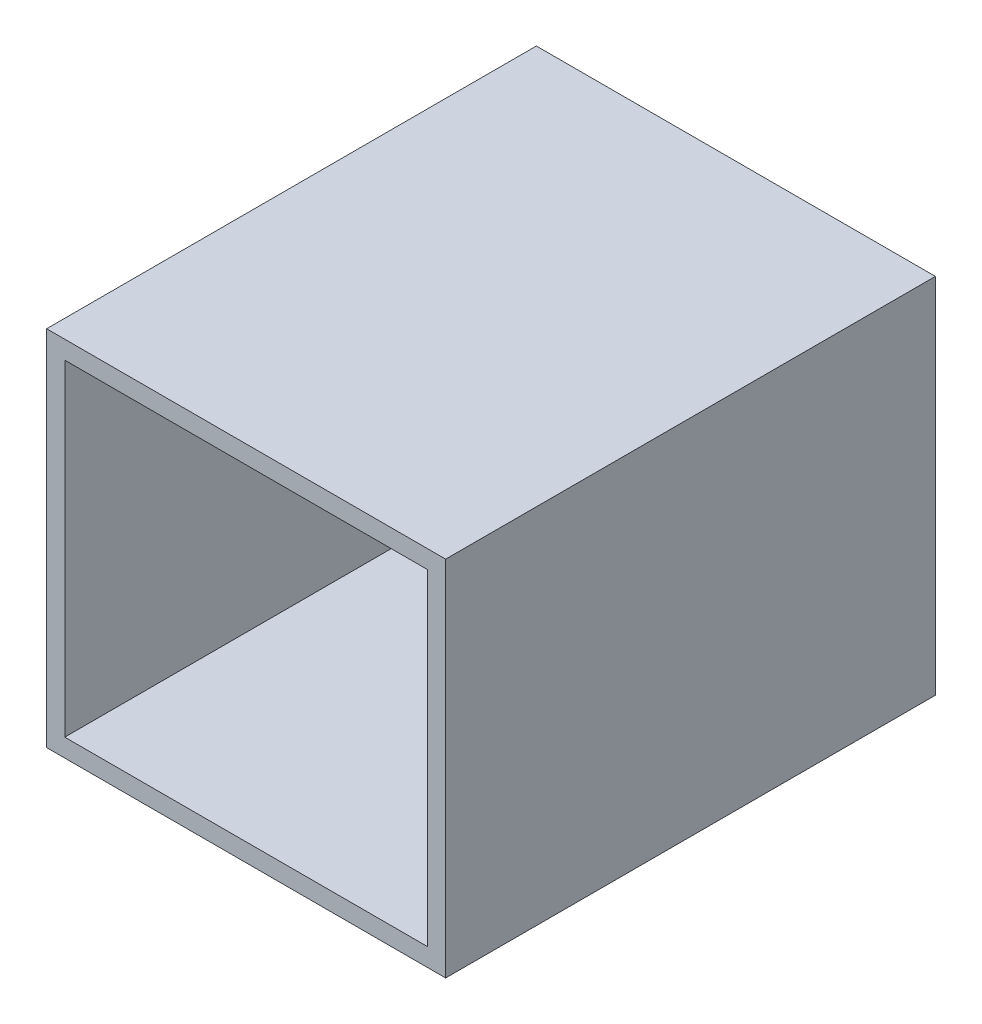
from build123d import *

# Parameters (mm, degrees)
SKETCH2_W           = 22
SKETCH2_H           = 20
SKETCH2_W_2         = 20
SKETCH2_H_2         = 18
BOSS_EXTRUDE1_DEPTH = 10
SKETCH2_2_W         = 20
SKETCH2_2_H         = 18
BOSS_EXTRUDE2_DEPTH = 1
SKETCH2_3_W         = 22
SKETCH2_3_H         = 20
SKETCH2_3_W_2       = 20
SKETCH2_3_H_2       = 18
BOSS_EXTRUDE3_DEPTH = 1
SKETCH2_4_W         = 22
SKETCH2_4_H         = 20
SKETCH2_4_W_2       = 20
SKETCH2_4_H_2       = 18
BOSS_EXTRUDE4_DEPTH = 26


with BuildPart() as part:
    # Sketch2 → Boss-Extrude1 (new body)
    with BuildSketch(Plane.XY):
        Rectangle(SKETCH2_W, SKETCH2_H)
        Rectangle(SKETCH2_W_2, SKETCH2_H_2, mode=Mode.SUBTRACT)
    extrude(amount=BOSS_EXTRUDE1_DEPTH)



with BuildPart() as body_2:
    # Sketch2_2 → Boss-Extrude2 (new body)
    with BuildSketch(Plane.XY):
        Rectangle(SKETCH2_2_W, SKETCH2_2_H)
    extrude(amount=-BOSS_EXTRUDE2_DEPTH)


with BuildPart() as part_1:
    add(part.part)

    add(body_2.part)  # Boss-Extrude3 merges body 2
    # Sketch2_3 → Boss-Extrude3 (add)
    with BuildSketch(Plane.XY):
        Rectangle(SKETCH2_3_W, SKETCH2_3_H)
        Rectangle(SKETCH2_3_W_2, SKETCH2_3_H_2, mode=Mode.SUBTRACT)
    extrude(amount=-BOSS_EXTRUDE3_DEPTH)

    # Sketch2_4 → Boss-Extrude4 (add)
    with BuildSketch(Plane.XY):
        Rectangle(SKETCH2_4_W, SKETCH2_4_H)
        Rectangle(SKETCH2_4_W_2, SKETCH2_4_H_2, mode=Mode.SUBTRACT)
    extrude(amount=BOSS_EXTRUDE4_DEPTH)


solid = part_1.part
